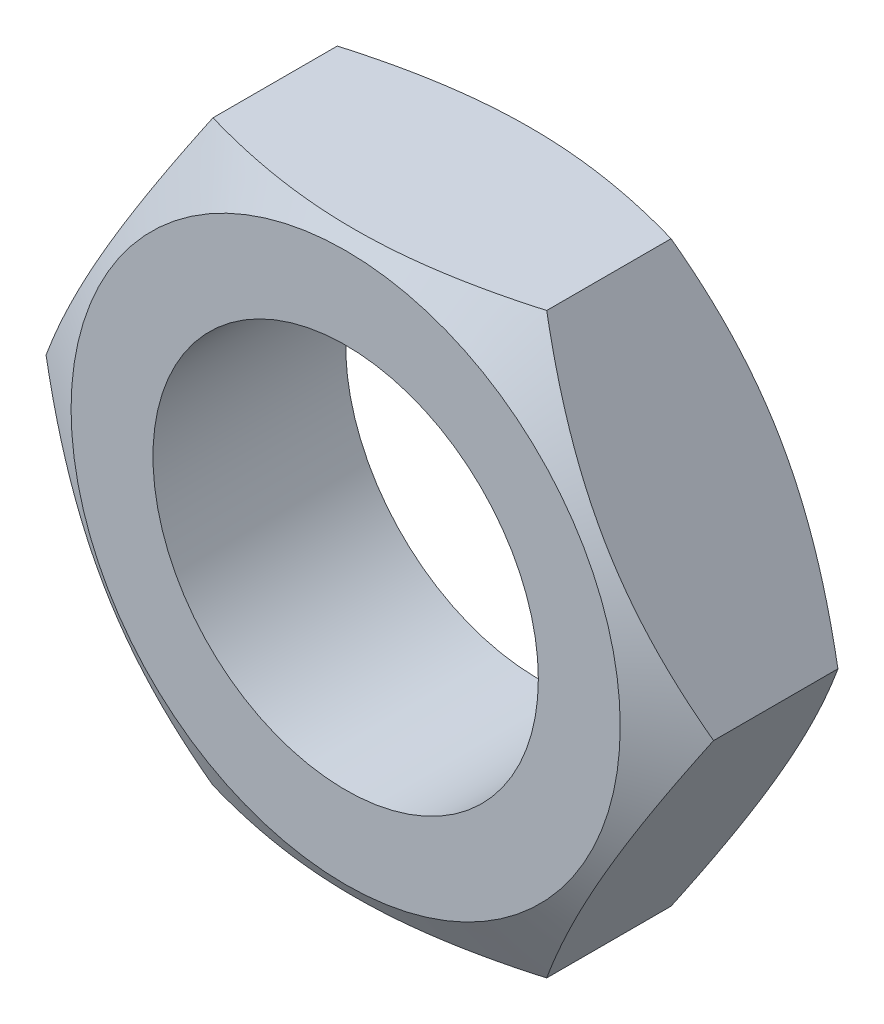
from build123d import *

# Parameters (mm, degrees)
BASENUTSKE_R       = 10
BASENUT_DEPTH      = 10
SKETCH6_OUTSIDE_W  = 84.128
SKETCH6_OUTSIDE_H  = 79.486
SKETCH6_OUTSIDE_R  = 14.25
CUT_EXTRUDE2_DEPTH = 11
CUT_EXTRUDE2_TAPER = 60


with BuildPart() as part:
    # BaseNutSke → BaseNut (new body)
    with BuildSketch(Plane.XY):
        Polygon((8.660254038, -15), (-8.660254038, -15), (-17.320508076, 0), (-8.660254038, 15), (8.660254038, 15), (17.320508076, 0), align=None)
        Circle(BASENUTSKE_R, mode=Mode.SUBTRACT)
    extrude(amount=-BASENUT_DEPTH)

    # Sketch6 outside → Cut-Extrude2 (cut, through all)
    with BuildSketch(Plane(origin=(0, 0, -10), x_dir=(-1, 0, 0), z_dir=(0, 0, -1))):
        Rectangle(SKETCH6_OUTSIDE_W, SKETCH6_OUTSIDE_H)
        Circle(SKETCH6_OUTSIDE_R, mode=Mode.SUBTRACT)
    cut_extrude2 = extrude(amount=-CUT_EXTRUDE2_DEPTH, taper=CUT_EXTRUDE2_TAPER, mode=Mode.SUBTRACT)

    # Mirror1: Cut-Extrude2 across plane
    add(cut_extrude2.mirror(Plane(origin=(0, 0, -5), x_dir=(1, 0, 0), z_dir=(0, 0, -1))), mode=Mode.SUBTRACT)


solid = part.part
